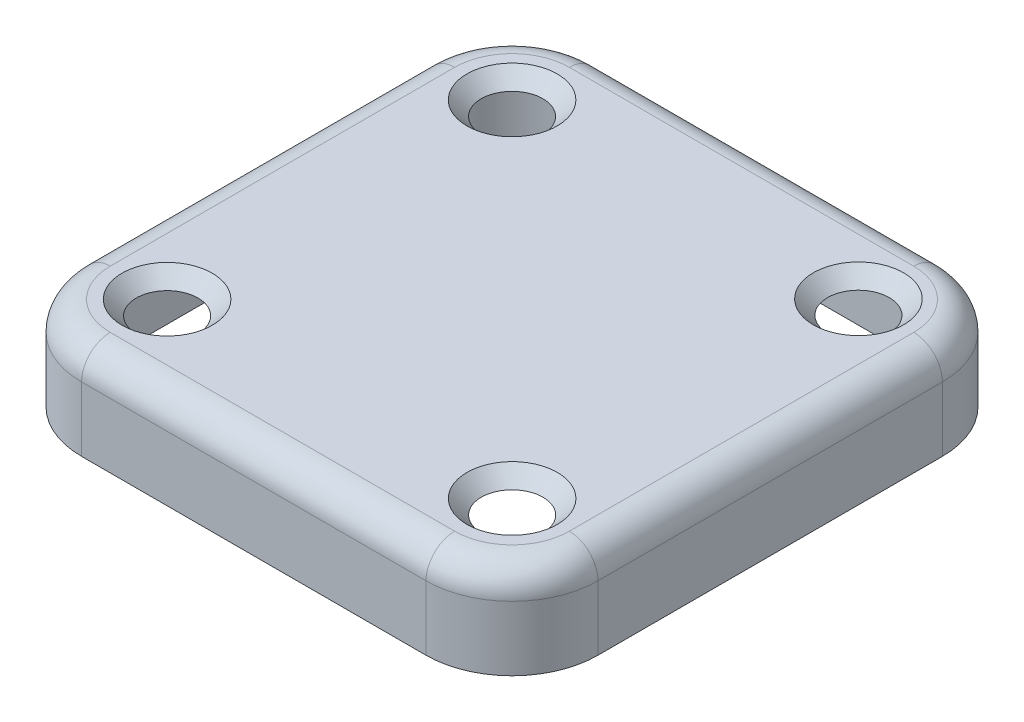
from build123d import *

# Parameters (mm, degrees)
BOSS_EXTRUDE1_DEPTH                          = 1
CSK_FOR_M3_COUNTERSUNK_FLAT_HEAD_SCR_2_COUNT = 2
CSK_FOR_M3_COUNTERSUNK_FLAT_HEAD_SCR_2_PITCH = 34.11906313
CSK_FOR_M3_COUNTERSUNK_FLAT_HEAD_SCR_3_COUNT = 2
CSK_FOR_M3_COUNTERSUNK_FLAT_HEAD_SCR_3_PITCH = 24.08237255
CSK_FOR_M3_COUNTERSUNK_FLAT_HEAD_SCR_4_COUNT = 2
CSK_FOR_M3_COUNTERSUNK_FLAT_HEAD_SCR_4_PITCH = 24.085156004
BOSS_EXTRUDE3_DEPTH                          = 5.5
FILLET1_R                                    = 2
FILLET2_R                                    = 1


with BuildPart() as part:
    # Sketch5 → Boss-Extrude1 (new body)
    with BuildSketch(Plane(origin=(0, 0, 0), x_dir=(1, 0, 0), z_dir=(0, 1, 0))):
        with BuildLine():
            Line((-18.02, 12.02), (-18.02, -12.02))
            ThreePointArc((-18.02, -12.02), (-16.262640687, -16.262640687), (-12.02, -18.02))
            Line((-12.02, -18.02), (12.02, -18.02))
            ThreePointArc((12.02, -18.02), (16.262640687, -16.262640687), (18.02, -12.02))
            Line((18.02, -12.02), (18.02, 12.02))
            ThreePointArc((18.02, 12.02), (16.262640687, 16.262640687), (12.02, 18.02))
            Line((12.02, 18.02), (-12.02, 18.02))
            ThreePointArc((-12.02, 18.02), (-16.262640687, 16.262640687), (-18.02, 12.02))
        make_face()
    extrude(amount=-BOSS_EXTRUDE1_DEPTH)

    # Sketch15 → CSK for M3 Countersunk Flat Head Screw3 (revolve, cut)
    with BuildSketch(Plane(origin=(-12.037863248, 0, 12.033949607), x_dir=(0, 0, 1), z_dir=(1, 0, 0))):
        Polygon((0, 0), (0, 1.001), (1.7, 1.001), (1.7, 1.45), (3.15, 0), align=None)
    csk_for_m3_countersunk_flat_head_screw3 = revolve(axis=Axis((-12.037863248, 6.35, 12.033949607), (0, -1, 0)), mode=Mode.SUBTRACT)

    # CSK for M3 Countersunk Flat Head Scr 2: CSK for M3 Countersunk Flat Head Screw3 ×2
    with Locations(*[Vector(0.706351229, 0, -0.707861527) * (i * CSK_FOR_M3_COUNTERSUNK_FLAT_HEAD_SCR_2_PITCH) for i in range(1, CSK_FOR_M3_COUNTERSUNK_FLAT_HEAD_SCR_2_COUNT)]):
        add(csk_for_m3_countersunk_flat_head_screw3, mode=Mode.SUBTRACT)

    # CSK for M3 Countersunk Flat Head Scr 3: CSK for M3 Countersunk Flat Head Screw3 ×2
    with Locations(*[(i * CSK_FOR_M3_COUNTERSUNK_FLAT_HEAD_SCR_3_PITCH, 0, 0) for i in range(1, CSK_FOR_M3_COUNTERSUNK_FLAT_HEAD_SCR_3_COUNT)]):
        add(csk_for_m3_countersunk_flat_head_screw3, mode=Mode.SUBTRACT)

    # CSK for M3 Countersunk Flat Head Scr 4: CSK for M3 Countersunk Flat Head Screw3 ×2
    with Locations(*[Vector(-0.000330161, 0, -0.999999945) * (i * CSK_FOR_M3_COUNTERSUNK_FLAT_HEAD_SCR_4_PITCH) for i in range(1, CSK_FOR_M3_COUNTERSUNK_FLAT_HEAD_SCR_4_COUNT)]):
        add(csk_for_m3_countersunk_flat_head_screw3, mode=Mode.SUBTRACT)

    # Sketch16 → Boss-Extrude3 (add)
    with BuildSketch(Plane.XZ.offset(1)):
        with BuildLine():
            Line((18.02, -12.02), (18.02, 12.02))
            ThreePointArc((18.02, 12.02), (16.262640687, 16.262640687), (12.02, 18.02))
            Line((12.02, 18.02), (-12.02, 18.02))
            ThreePointArc((-12.02, 18.02), (-16.262640687, 16.262640687), (-18.02, 12.02))
            Line((-18.02, 12.02), (-18.02, -12.02))
            ThreePointArc((-18.02, -12.02), (-16.262640687, -16.262640687), (-12.02, -18.02))
            Line((-12.02, -18.02), (12.02, -18.02))
            ThreePointArc((12.02, -18.02), (16.262640687, -16.262640687), (18.02, -12.02))
        make_face()
        with BuildLine():
            Line((17.02, -12.02), (17.02, 12.02))
            ThreePointArc((17.02, 12.02), (15.555533906, 15.555533906), (12.02, 17.02))
            Line((12.02, 17.02), (-12.02, 17.02))
            ThreePointArc((-12.02, 17.02), (-15.555533906, 15.555533906), (-17.02, 12.02))
            Line((-17.02, 12.02), (-17.02, -12.02))
            ThreePointArc((-17.02, -12.02), (-15.555533906, -15.555533906), (-12.02, -17.02))
            Line((-12.02, -17.02), (12.02, -17.02))
            ThreePointArc((12.02, -17.02), (15.555533906, -15.555533906), (17.02, -12.02))
        make_face(mode=Mode.SUBTRACT)
    extrude(amount=BOSS_EXTRUDE3_DEPTH)

    # Fillet1
    fillet1_edges = [part.edges().sort_by_distance(p)[0] for p in [
        (16.262640687, 0, 16.262640687),
        (0, 0, 18.02),
        (-16.262640687, 0, 16.262640687),
        (-18.02, 0, 0),
        (-16.262640687, 0, -16.262640687),
        (0, 0, -18.02),
        (16.262640687, 0, -16.262640687),
        (18.02, 0, 0),
    ]]
    fillet(fillet1_edges, radius=FILLET1_R)

    # Fillet2
    fillet2_edges = [part.edges().sort_by_distance(p)[0] for p in [
        (15.555533906, -1, -15.555533906),
        (17.02, -1, 0),
        (15.555533906, -1, 15.555533906),
        (0, -1, 17.02),
        (-15.555533906, -1, 15.555533906),
        (-17.02, -1, 0),
        (-15.555533906, -1, -15.555533906),
        (0, -1, -17.02),
    ]]
    fillet(fillet2_edges, radius=FILLET2_R)


solid = part.part
